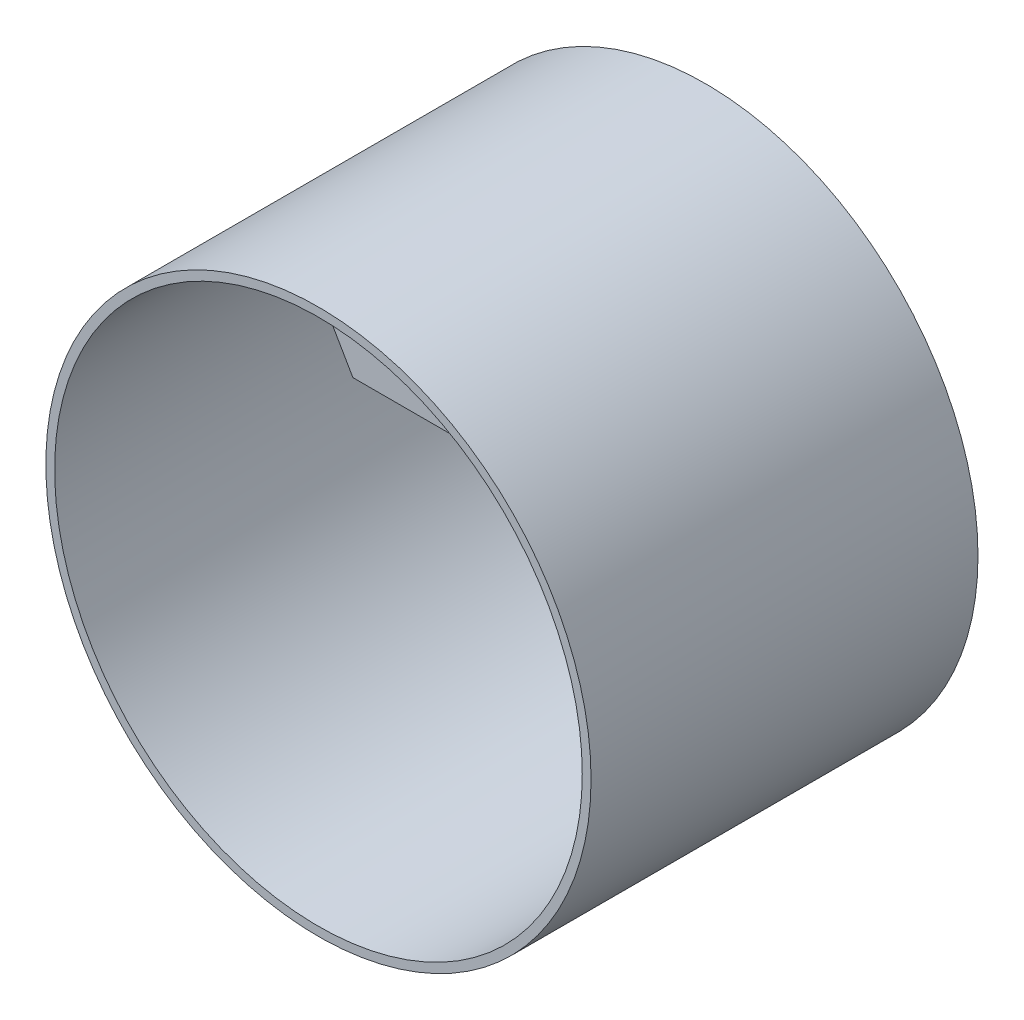
from build123d import *

# Parameters (mm, degrees)
SKETCH_1_R      = 155
SKETCH_1_R_2    = 150
EXTRUDE_1_DEPTH = 110
EXTRUDE_2_DEPTH = 50


with BuildPart() as part:
    # 草图1 → 凸台-拉伸1 (new body, symmetric)
    with BuildSketch(Plane.XY):
        Circle(SKETCH_1_R)
        Circle(SKETCH_1_R_2, mode=Mode.SUBTRACT)
    extrude(amount=EXTRUDE_1_DEPTH, both=True)

    # 草图2 → 凸台-拉伸2 (add, symmetric)
    with BuildSketch(Plane.XY):
        with BuildLine():
            Line((-40.414518843, 70), (-75, 129.903810568))
            ThreePointArc((-75, 129.903810568), (0, 150), (75, 129.903810568))
            Line((75, 129.903810568), (40.414518843, 70))
            Line((40.414518843, 70), (-40.414518843, 70))
        make_face()
    extrude(amount=EXTRUDE_2_DEPTH, both=True)


solid = part.part
